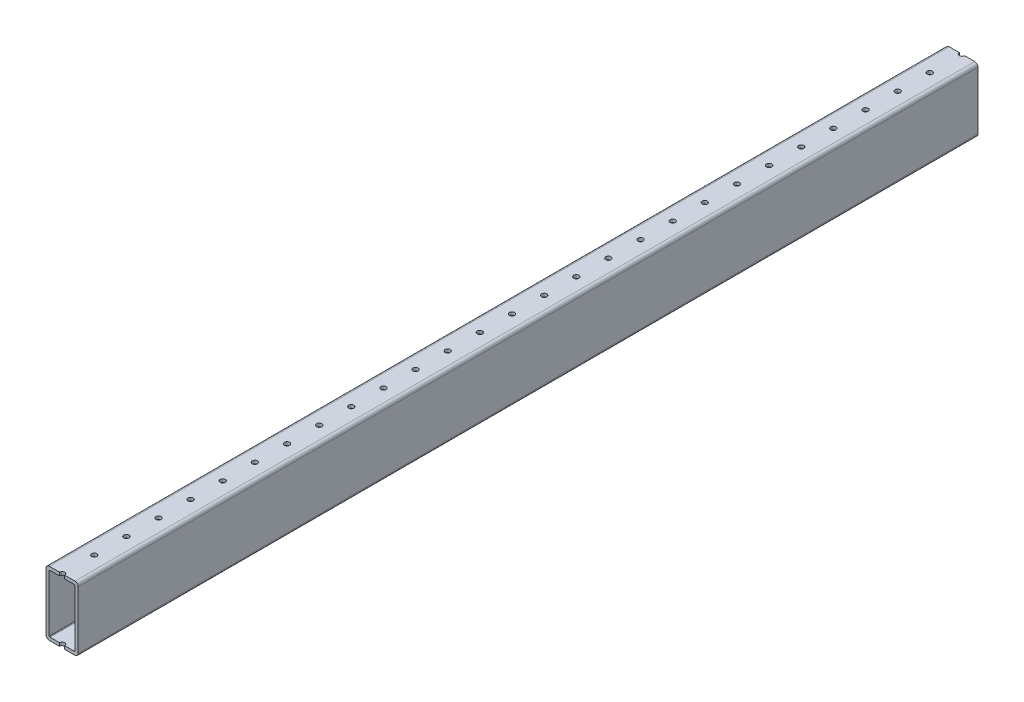
from build123d import *

# Parameters (mm, degrees)
SKETCH1_W                 = 711.2
SKETCH1_H                 = 50.8
BOSS_EXTRUDE1_DEPTH       = 25.4
SKETCH2_W                 = 20.32
SKETCH2_H                 = 45.72
CUT_EXTRUDE1_DEPTH        = 712.2
F_6_CLEARANCE_HOLE1_D     = 4.1402
F_6_CLEARANCE_HOLE1_DEPTH = 50.8
F_6_CLEARANCE_HOLE2_D     = 4.1402
F_6_CLEARANCE_HOLE2_DEPTH = 50.8
FILLET1_R                 = 0.5
FILLET2_R                 = 2.54


with BuildPart() as part:
    # Sketch1 → Boss-Extrude1 (new body)
    with BuildSketch(Plane(origin=(12.7, 0, 0), x_dir=(0, 0, -1), z_dir=(1, 0, 0))):
        Rectangle(SKETCH1_W, SKETCH1_H)
    extrude(amount=-BOSS_EXTRUDE1_DEPTH)

    # Sketch2 → Cut-Extrude1 (cut, through all)
    with BuildSketch(Plane(origin=(0, 0, -355.6), x_dir=(-1, 0, 0), z_dir=(0, 0, -1))):
        Rectangle(SKETCH2_W, SKETCH2_H)
    extrude(amount=-CUT_EXTRUDE1_DEPTH, mode=Mode.SUBTRACT)

    # #6 Clearance Hole1
    with Locations(Plane(origin=(0, -25.4, 0), x_dir=(-1, 0, 0), z_dir=(0, -1, 0))):
        with Locations((0, 711.2), (0, 736.6), (0, 685.8), (0, 660.4), (0, 635), (0, 609.6), (0, 584.2), (0, 558.8), (0, 533.4), (0, 508), (0, 482.6), (0, 457.2), (0, 431.8), (0, 406.4), (0, 381), (0, 355.6), (0, 330.2), (0, 304.8), (0, 279.4), (0, 254), (0, 228.6), (0, 203.2), (0, 177.8), (0, 152.4), (0, 127), (0, 101.6), (0, 76.2), (0, 50.8), (0, 25.4), (0, 0), (0, -25.4), (0, -50.8), (0, -76.2), (0, -101.6), (0, -127), (0, -152.4), (0, -177.8), (0, -203.2), (0, -228.6), (0, -254), (0, -279.4), (0, -304.8), (0, -330.2), (0, -355.6), (0, -381), (0, -406.4), (0, -431.8), (0, -457.2), (0, -482.6), (0, -508), (0, -533.4), (0, -558.8), (0, -584.2), (0, -609.6), (0, -635), (0, -660.4), (0, -685.8), (0, -711.2), (0, -736.6)):
            Hole(F_6_CLEARANCE_HOLE1_D / 2, depth=F_6_CLEARANCE_HOLE1_DEPTH)

    # #6 Clearance Hole2
    with Locations(Plane(origin=(0, 25.4, 0), x_dir=(1, 0, 0), z_dir=(0, 1, 0))):
        with Locations((0, 711.2), (0, 736.6), (0, 685.8), (0, 660.4), (0, 635), (0, 609.6), (0, 584.2), (0, 558.8), (0, 533.4), (0, 508), (0, 482.6), (0, 457.2), (0, 431.8), (0, 406.4), (0, 381), (0, 355.6), (0, 330.2), (0, 304.8), (0, 279.4), (0, 254), (0, 228.6), (0, 203.2), (0, 177.8), (0, 152.4), (0, 127), (0, 101.6), (0, 76.2), (0, 50.8), (0, 25.4), (0, 0), (0, -25.4), (0, -50.8), (0, -76.2), (0, -101.6), (0, -127), (0, -152.4), (0, -177.8), (0, -203.2), (0, -228.6), (0, -254), (0, -279.4), (0, -304.8), (0, -330.2), (0, -355.6), (0, -381), (0, -406.4), (0, -431.8), (0, -457.2), (0, -482.6), (0, -508), (0, -533.4), (0, -558.8), (0, -584.2), (0, -609.6), (0, -635), (0, -660.4), (0, -685.8), (0, -711.2), (0, -736.6)):
            Hole(F_6_CLEARANCE_HOLE2_D / 2, depth=F_6_CLEARANCE_HOLE2_DEPTH)

    # Fillet1
    fillet1_edges = [part.edges().sort_by_distance(p)[0] for p in [
        (-10.16, -22.86, 0),
        (10.16, -22.86, 0),
        (10.16, 22.86, 0),
        (-10.16, 22.86, 0),
    ]]
    fillet(fillet1_edges, radius=FILLET1_R)

    # Fillet2
    fillet2_edges = [part.edges().sort_by_distance(p)[0] for p in [
        (-12.7, 25.4, 0),
        (-12.7, -25.4, 0),
        (12.7, 25.4, 0),
        (12.7, -25.4, 0),
    ]]
    fillet(fillet2_edges, radius=FILLET2_R)


solid = part.part
